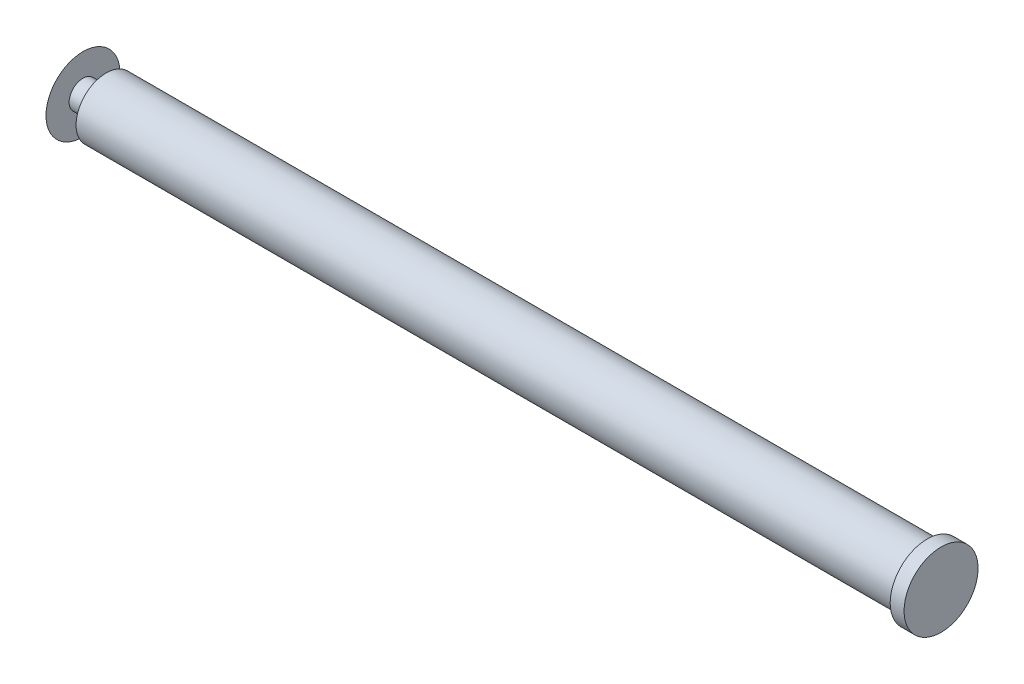
from build123d import *


with BuildPart() as part:
    # Sketch1 → Revolve1 (revolve)
    with BuildSketch(Plane.XY):
        with BuildLine():
            Line((319.632932386, 0), (319.632932386, 16))
            Line((319.632932386, 16), (313.632932386, 16))
            Line((313.632932386, 16), (313.632932386, 13))
            Line((313.632932386, 13), (-41.367067614, 13))
            Line((-41.367067614, 13), (-41.367067614, 6))
            Line((-41.367067614, 6), (-51.367067614, 6))
            Line((-51.367067614, 6), (-51.367067614, 16))
            ThreePointArc((-51.367067614, 16), (-54.351912619, 8.246211251), (-55.367067614, 0))
            Line((-55.367067614, 0), (319.632932386, 0))
        make_face()
    revolve(axis=Axis((-129.812073534, 0, 0), (1, 0, 0)))


solid = part.part
